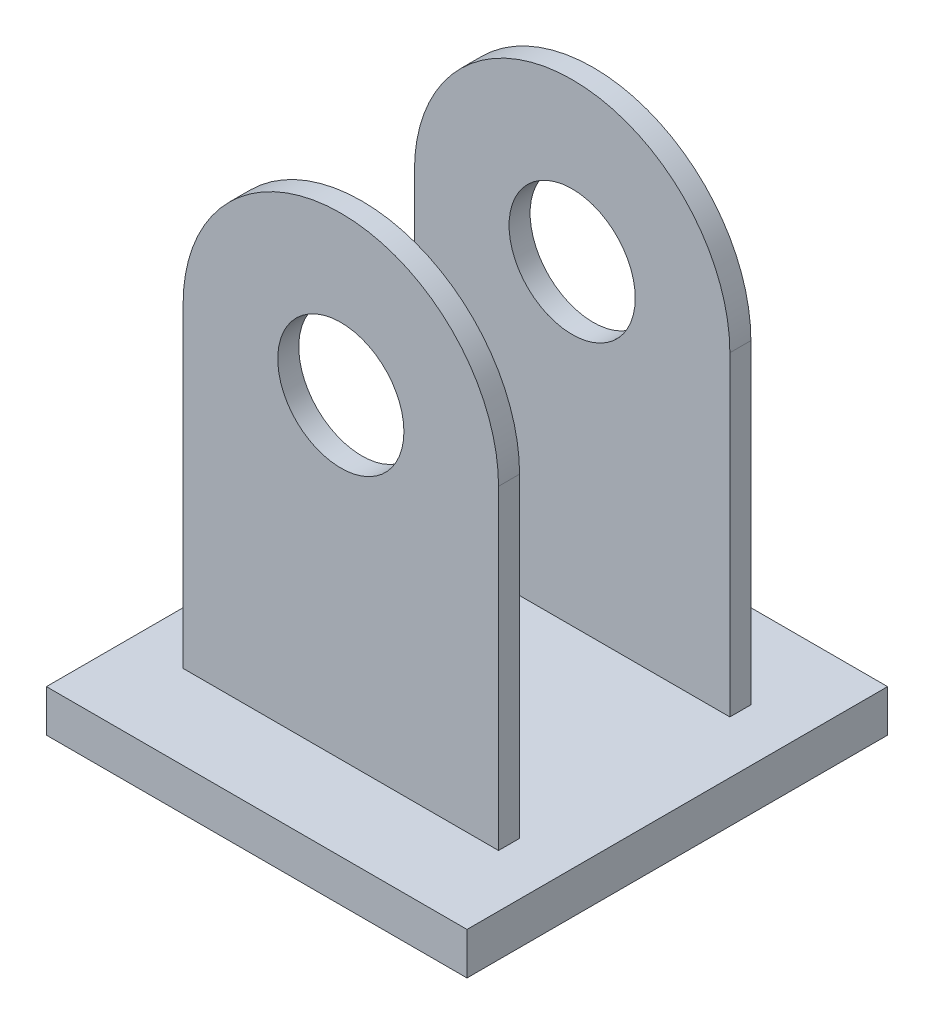
from build123d import *

# Parameters (mm, degrees)
SKETCH1_W           = 20
SKETCH1_H           = 20
BOSS_EXTRUDE1_DEPTH = 2
SKETCH4_R           = 3
BOSS_EXTRUDE2_DEPTH = 1


with BuildPart() as part:
    # Sketch1 → Boss-Extrude1 (new body)
    with BuildSketch(Plane(origin=(0, 0, 0), x_dir=(1, 0, 0), z_dir=(0, 1, 0))):
        Rectangle(SKETCH1_W, SKETCH1_H)
    extrude(amount=BOSS_EXTRUDE1_DEPTH)

    # Sketch4 → Boss-Extrude2 (add)
    with BuildSketch(Plane.XY.offset(5)):
        with BuildLine():
            Line((-7.5, 17), (-7.5, 2))
            Line((-7.5, 2), (7.5, 2))
            Line((7.5, 2), (7.5, 17))
            ThreePointArc((7.5, 17), (0, 24.5), (-7.5, 17))
        make_face()
        with Locations((0, 17)):
            Circle(SKETCH4_R, mode=Mode.SUBTRACT)
    boss_extrude2 = extrude(amount=BOSS_EXTRUDE2_DEPTH)

    # Mirror1: Boss-Extrude2 across plane
    add(boss_extrude2.mirror(Plane.XY))


solid = part.part
